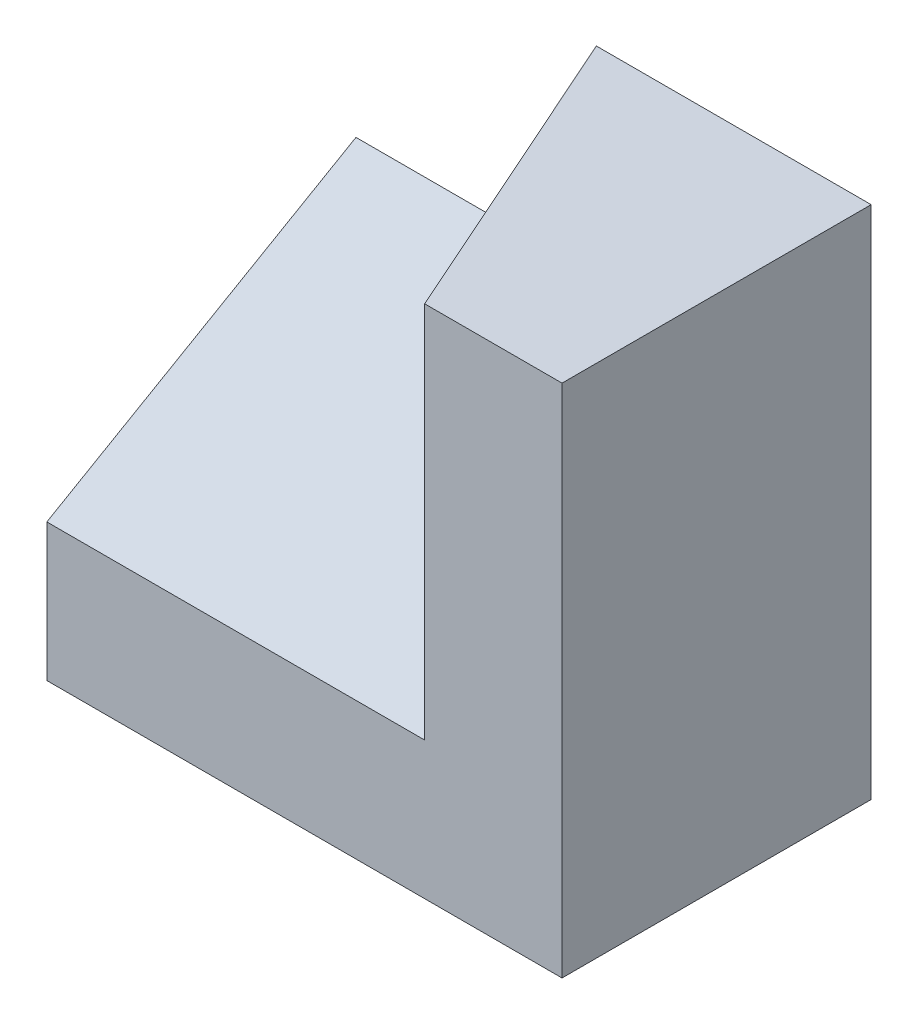
from build123d import *

# Parameters (mm, degrees)
EXTRUDE1_DEPTH = 75
EXTRUDE2_DEPTH = 75


with BuildPart() as part:
    # Sketch1 → Extrude1 (new body)
    with BuildSketch(Plane(origin=(0, 0, 0), x_dir=(1, 0, 0), z_dir=(0, 1, 0))):
        Polygon((0, 0), (0, -45), (-20, -45), (-40, 0), align=None)
    extrude(amount=EXTRUDE1_DEPTH)

    # Sketch2 → Extrude2 (add)
    with BuildSketch(Plane(origin=(0, 0, 0), x_dir=(0, 0, -1), z_dir=(1, 0, 0))):
        Polygon((-45, 20), (-45, 0), (0, 0), (0, 45.980762114), align=None)
    extrude(amount=-EXTRUDE2_DEPTH)


solid = part.part
